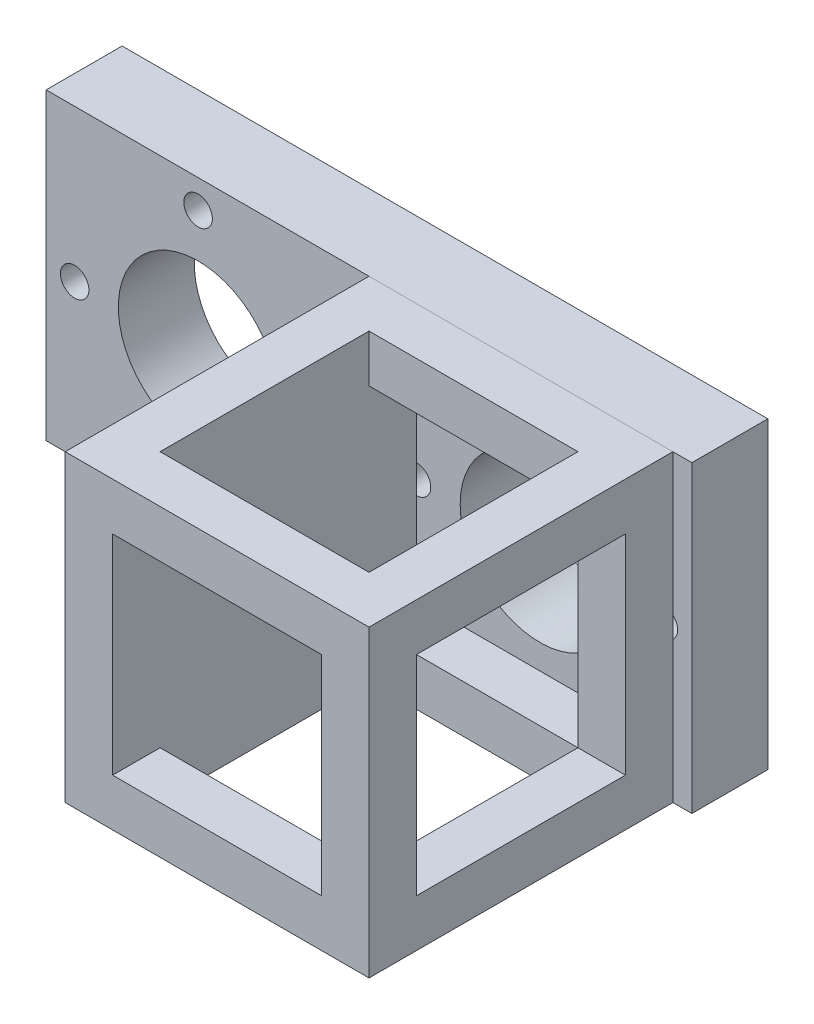
from build123d import *

# Parameters (mm, degrees)
ESQUISSE2_W                  = 34
ESQUISSE2_H                  = 32
ESQUISSE2_R                  = 8.4
BOSS_EXTRU_1_DEPTH           = 8
ESQUISSE4_R                  = 1.5
ENL_V_MAT_EXTRU_1_DEPTH      = 8
R_P_TITION_CIRCULAIRE1_COUNT = 4
ESQUISSE10_W                 = 32
ESQUISSE10_H                 = 32
BOSS_EXTRU_4_DEPTH           = 32
SYM_TRIE1_COPY_1_SKETCH_R    = 1.5
SYM_TRIE1_COPY_1_DEPTH       = 8
SYM_TRIE1_COPY_2_SKETCH_R    = 1.5
SYM_TRIE1_COPY_2_DEPTH       = 8
SYM_TRIE1_COPY_3_SKETCH_R    = 1.5
SYM_TRIE1_COPY_3_DEPTH       = 8
ESQUISSE12_W                 = 22
ESQUISSE12_H                 = 22
ENL_V_MAT_EXTRU_4_DEPTH      = 18
ESQUISSE11_W                 = 22
ESQUISSE11_H                 = 22
ENL_V_MAT_EXTRU_5_DEPTH      = 62.481704596
ESQUISSE13_W                 = 22
ESQUISSE13_H                 = 22
ENL_V_MAT_EXTRU_6_DEPTH      = 32


with BuildPart() as part:
    # Esquisse2 → Boss.-Extru.1 (new body)
    with BuildSketch(Plane.XY):
        with Locations((-17, 0)):
            Rectangle(ESQUISSE2_W, ESQUISSE2_H)
        with Locations((-18, 0)):
            Circle(ESQUISSE2_R, mode=Mode.SUBTRACT)
    boss_extru_1 = extrude(amount=BOSS_EXTRU_1_DEPTH)

    # Esquisse4 → Enlèv. mat.-Extru.1 (cut)
    with BuildSketch(Plane.XY.offset(8)):
        with Locations((-31, 0)):
            Circle(ESQUISSE4_R)
    enl_v_mat_extru_1 = extrude(amount=-ENL_V_MAT_EXTRU_1_DEPTH, mode=Mode.SUBTRACT)

    # Répétition circulaire1: Enlèv. mat.-Extru.1 ×4 about axis
    r_p_tition_circulaire1_axis = Axis((-18, 0, 0), (0, 0, 1))
    for i in range(1, R_P_TITION_CIRCULAIRE1_COUNT):
        add(enl_v_mat_extru_1.rotate(r_p_tition_circulaire1_axis, i * 360 / R_P_TITION_CIRCULAIRE1_COUNT), mode=Mode.SUBTRACT)

    # Symétrie1: Boss.-Extru.1, Enlèv. mat.-Extru.1 across plane
    add(boss_extru_1.mirror(Plane(origin=(0, 0, 0), x_dir=(0, 0, 1), z_dir=(1, 0, 0))))
    add(enl_v_mat_extru_1.mirror(Plane(origin=(0, 0, 0), x_dir=(0, 0, 1), z_dir=(1, 0, 0))), mode=Mode.SUBTRACT)

    # Symétrie1 copy 1 sketch → Symétrie1 copy 1 (cut)
    with BuildSketch(Plane(origin=(18, 18, 8), x_dir=(0, 1, 0), z_dir=(0, 0, 1))):
        with Locations((-31, 0)):
            Circle(SYM_TRIE1_COPY_1_SKETCH_R)
    extrude(amount=-SYM_TRIE1_COPY_1_DEPTH, mode=Mode.SUBTRACT)

    # Symétrie1 copy 2 sketch → Symétrie1 copy 2 (cut)
    with BuildSketch(Plane(origin=(36, 0, 8), x_dir=(1, 0, 0), z_dir=(0, 0, 1))):
        with Locations((-31, 0)):
            Circle(SYM_TRIE1_COPY_2_SKETCH_R)
    extrude(amount=-SYM_TRIE1_COPY_2_DEPTH, mode=Mode.SUBTRACT)

    # Symétrie1 copy 3 sketch → Symétrie1 copy 3 (cut)
    with BuildSketch(Plane(origin=(18, -18, 8), x_dir=(0, -1, 0), z_dir=(0, 0, 1))):
        with Locations((-31, 0)):
            Circle(SYM_TRIE1_COPY_3_SKETCH_R)
    extrude(amount=-SYM_TRIE1_COPY_3_DEPTH, mode=Mode.SUBTRACT)


with BuildPart() as body_2:
    # Esquisse10 → Boss.-Extru.4 (new body)
    with BuildSketch(Plane(origin=(0, 0, 0), x_dir=(0, 0, -1), z_dir=(1, 0, 0))):
        with Locations((-24, 0)):
            Rectangle(ESQUISSE10_W, ESQUISSE10_H)
    extrude(amount=BOSS_EXTRU_4_DEPTH)

    # Esquisse12 → Enlèv. mat.-Extru.4 (cut)
    with BuildSketch(Plane(origin=(32, 0, 0), x_dir=(0, 0, -1), z_dir=(1, 0, 0))):
        with Locations((-24, 0)):
            Rectangle(ESQUISSE12_W, ESQUISSE12_H)
    extrude(amount=-ENL_V_MAT_EXTRU_4_DEPTH, mode=Mode.SUBTRACT)

    # Esquisse11 → Enlèv. mat.-Extru.5 (cut, through all)
    with BuildSketch(Plane.XZ.offset(16)):
        with Locations((16, 24)):
            Rectangle(ESQUISSE11_W, ESQUISSE11_H)
    extrude(amount=-ENL_V_MAT_EXTRU_5_DEPTH, mode=Mode.SUBTRACT)

    # Esquisse13 → Enlèv. mat.-Extru.6 (cut)
    with BuildSketch(Plane.XY.offset(40)):
        with Locations((16, 0)):
            Rectangle(ESQUISSE13_W, ESQUISSE13_H)
    extrude(amount=-ENL_V_MAT_EXTRU_6_DEPTH, mode=Mode.SUBTRACT)


solid = Compound([part.part, body_2.part])
